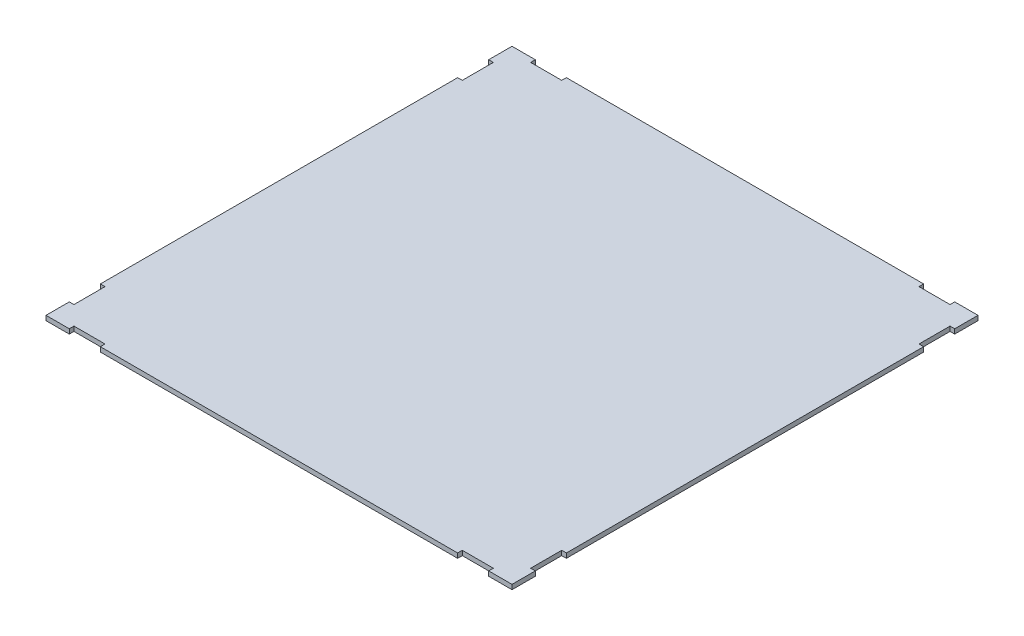
from build123d import *

# Parameters (mm, degrees)
SALIENTE_EXTRUIR1_DEPTH = 3


with BuildPart() as part:
    # Croquis1 → Saliente-Extruir1 (new body)
    with BuildSketch(Plane(origin=(0, 0, 0), x_dir=(1, 0, 0), z_dir=(0, 1, 0))):
        Polygon((0, 0), (15, 0), (15, 3), (35, 3), (35, 0), (265, 0), (265, 3), (285, 3), (285, 0), (300, 0), (300, 15), (297, 15), (297, 35), (300, 35), (300, 265), (297, 265), (297, 285), (300, 285), (300, 300), (285, 300), (285, 297), (265, 297), (265, 300), (35, 300), (35, 297), (15, 297), (15, 300), (0, 300), (0, 285), (3, 285), (3, 265), (0, 265), (0, 35), (3, 35), (3, 15), (0, 15), align=None)
    extrude(amount=SALIENTE_EXTRUIR1_DEPTH)


solid = part.part
